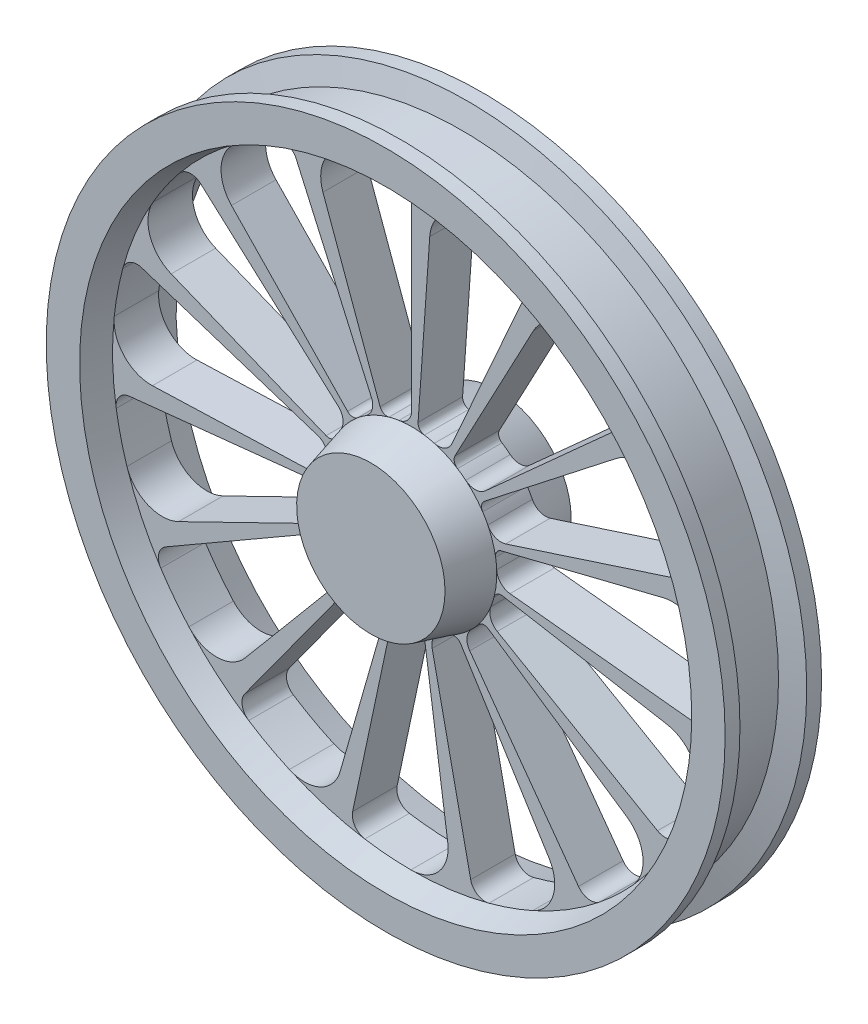
from build123d import *

# Parameters (mm, degrees)
CUT_EXTRUDE1_REACH = 117


with BuildPart() as part:
    # Sketch1 → Revolve2 (revolve)
    with BuildSketch(Plane(origin=(0, 0, 0), x_dir=(0, 0, -1), z_dir=(1, 0, 0))):
        Polygon((0, 0), (170, 0), (170, 100), (115, 114.737205584), (115, 403.121778265), (150, 412.5), (150, 457.5), (130, 457.5), (121.961524227, 427.5), (48.038475773, 427.5), (40, 457.5), (20, 457.5), (20, 412.5), (55, 403.121778265), (55, 114.737205584), (0, 100), align=None)
    revolve(axis=Axis((0, 0, 0), (0, 0, -1)))

    # Sketch3 → Cut-Extrude1 (cut, up to next)
    with BuildSketch(Plane(origin=(0, 0, -115), x_dir=(-1, 0, 0), z_dir=(0, 0, -1)), mode=Mode.PRIVATE) as cut_extrude1_sk1:
        with BuildLine():
            ThreePointArc((21.044054457, 402.57212507), (6.231940753, 397.105963918), (0, 382.599394904))
            Line((0, 382.599394904), (0, 133.24456675))
            ThreePointArc((0, 133.24456675), (4.844558076, 120.194180546), (17.031258009, 113.46612973))
            ThreePointArc((17.031258009, 113.46612973), (23.794589812, 112.242789705), (30.472538424, 110.616683855))
            ThreePointArc((30.472538424, 110.616683855), (37.714753572, 111.371314729), (42.525319659, 116.837355519))
            Line((42.525319659, 116.837355519), (119.557929474, 328.482711546))
            ThreePointArc((119.557929474, 328.482711546), (116.274613155, 369.877649884), (82.849257452, 394.516373109))
            ThreePointArc((82.849257452, 394.516373109), (52.102580068, 399.74052742), (21.044054457, 402.57212507))
        make_face()
    cut_extrude1_tool1 = extrude(cut_extrude1_sk1.sketch, amount=-CUT_EXTRUDE1_REACH, mode=Mode.PRIVATE) & part.part
    add(cut_extrude1_tool1.solids().sort_by_distance((-47.75418, 277.635932, -115))[0], mode=Mode.SUBTRACT)
    # Sketch3 → Cut-Extrude1 (cut, up to next)
    with BuildSketch(Plane(origin=(0, 0, -115), x_dir=(-1, 0, 0), z_dir=(0, 0, -1)), mode=Mode.PRIVATE) as cut_extrude1_sk2:
        with BuildLine():
            ThreePointArc((236.150828051, 326.710811762), (210.187195577, 343.989114547), (182.965535106, 359.208548165))
            ThreePointArc((182.965535106, 359.208548165), (167.210707876, 360.239590879), (155.617193526, 349.521939311))
            Line((155.617193526, 349.521939311), (54.195447788, 121.72496871))
            ThreePointArc((54.195447788, 121.72496871), (53.313101537, 107.832388384), (61.709661101, 96.729230701))
            ThreePointArc((61.709661101, 96.729230701), (67.390694934, 92.860759105), (72.82990772, 88.659071091))
            ThreePointArc((72.82990772, 88.659071091), (79.7529365, 86.40278642), (86.370846379, 89.439629654))
            Line((86.370846379, 89.439629654), (242.827558799, 251.45529816))
            ThreePointArc((242.827558799, 251.45529816), (256.664938349, 290.606901105), (236.150828051, 326.710811762))
        make_face()
    cut_extrude1_tool2 = extrude(cut_extrude1_sk2.sketch, amount=-CUT_EXTRUDE1_REACH, mode=Mode.PRIVATE) & part.part
    add(cut_extrude1_tool2.solids().sort_by_distance((-156.550321, 234.20967, -115))[0], mode=Mode.SUBTRACT)
    # Sketch3 → Cut-Extrude1 (cut, up to next)
    with BuildSketch(Plane(origin=(0, 0, -115), x_dir=(-1, 0, 0), z_dir=(0, 0, -1)), mode=Mode.PRIVATE) as cut_extrude1_sk3:
        with BuildLine():
            ThreePointArc((348.619775118, 202.413982986), (331.928535479, 228.758858727), (313.250612546, 253.734549975))
            ThreePointArc((313.250612546, 253.734549975), (299.277224547, 261.084519902), (284.326760554, 256.008965105))
            Line((284.326760554, 256.008965105), (99.020010304, 89.158017744))
            ThreePointArc((99.020010304, 89.158017744), (92.563325408, 76.825396644), (95.717903174, 63.266968927))
            ThreePointArc((95.717903174, 63.266968927), (99.334336676, 57.422259641), (102.594324332, 51.371499492))
            ThreePointArc((102.594324332, 51.371499492), (108.001112174, 46.494431395), (115.282069106, 46.576979287))
            Line((115.282069106, 46.576979287), (324.110097188, 130.948979322))
            ThreePointArc((324.110097188, 130.948979322), (352.675563975, 161.087579045), (348.619775118, 202.413982986))
        make_face()
    cut_extrude1_tool3 = extrude(cut_extrude1_sk3.sketch, amount=-CUT_EXTRUDE1_REACH, mode=Mode.PRIVATE) & part.part
    add(cut_extrude1_tool3.solids().sort_by_distance((-238.27749, 150.286428, -115))[0], mode=Mode.SUBTRACT)
    # Sketch3 → Cut-Extrude1 (cut, up to next)
    with BuildSketch(Plane(origin=(0, 0, -115), x_dir=(-1, 0, 0), z_dir=(0, 0, -1)), mode=Mode.PRIVATE) as cut_extrude1_sk4:
        with BuildLine():
            ThreePointArc((400.809195955, 43.11793768), (396.276416122, 73.974118023), (389.371813284, 104.387542988))
            ThreePointArc((389.371813284, 104.387542988), (379.595990245, 116.785563556), (363.873647654, 118.229715063))
            Line((363.873647654, 118.229715063), (126.723113469, 41.174835534))
            ThreePointArc((126.723113469, 41.174835534), (115.808509405, 32.534595887), (113.175650218, 18.865273462))
            ThreePointArc((113.175650218, 18.865273462), (114.102169183, 12.054929821), (114.619250226, 5.201328936))
            ThreePointArc((114.619250226, 5.201328936), (117.574914394, -1.453233208), (124.259974779, -4.339253936))
            Line((124.259974779, -4.339253936), (349.351055326, -12.199607675))
            ThreePointArc((349.351055326, -12.199607675), (387.705380633, 3.714751133), (400.809195955, 43.11793768))
        make_face()
    cut_extrude1_tool4 = extrude(cut_extrude1_sk4.sketch, amount=-CUT_EXTRUDE1_REACH, mode=Mode.PRIVATE) & part.part
    add(cut_extrude1_tool4.solids().sort_by_distance((-278.804316, 40.377297, -115))[0], mode=Mode.SUBTRACT)
    # Sketch3 → Cut-Extrude1 (cut, up to next)
    with BuildSketch(Plane(origin=(0, 0, -115), x_dir=(-1, 0, 0), z_dir=(0, 0, -1)), mode=Mode.PRIVATE) as cut_extrude1_sk5:
        with BuildLine():
            ThreePointArc((383.695065574, -123.633590766), (392.104504358, -93.60141972), (398.167090174, -63.009018512))
            ThreePointArc((398.167090174, -63.009018512), (394.279160708, -47.706677692), (380.503475387, -39.992526796))
            Line((380.503475387, -39.992526796), (132.514639072, -13.927849801))
            ThreePointArc((132.514639072, -13.927849801), (119.029350038, -17.381732066), (111.064299172, -28.798399169))
            ThreePointArc((111.064299172, -28.798399169), (109.140700052, -35.39680688), (106.825466474, -41.868198646))
            ThreePointArc((106.825466474, -41.868198646), (106.818945781, -49.149620586), (111.752201947, -54.505190733))
            Line((111.752201947, -54.505190733), (314.186042243, -153.238771675))
            ThreePointArc((314.186042243, -153.238771675), (355.697414787, -154.300390997), (383.695065574, -123.633590766))
        make_face()
    cut_extrude1_tool5 = extrude(cut_extrude1_sk5.sketch, amount=-CUT_EXTRUDE1_REACH, mode=Mode.PRIVATE) & part.part
    add(cut_extrude1_tool5.solids().sort_by_distance((-271.123342, -76.513435, -115))[0], mode=Mode.SUBTRACT)
    # Sketch3 → Cut-Extrude1 (cut, up to next)
    with BuildSketch(Plane(origin=(0, 0, -115), x_dir=(-1, 0, 0), z_dir=(0, 0, -1)), mode=Mode.PRIVATE) as cut_extrude1_sk6:
        with BuildLine():
            ThreePointArc((300.236572595, -269.007748193), (320.134161633, -244.992421652), (338.115659938, -219.510748293))
            ThreePointArc((338.115659938, -219.510748293), (340.787882371, -203.950000966), (331.340795459, -191.299697452))
            Line((331.340795459, -191.299697452), (115.393179722, -66.622283375))
            ThreePointArc((115.393179722, -66.622283375), (101.668934702, -64.292600637), (89.74892181, -71.482566959))
            ThreePointArc((89.74892181, -71.482566959), (85.30781237, -76.728114103), (80.560589089, -81.698334321))
            ThreePointArc((80.560589089, -81.698334321), (77.593011023, -88.347592055), (79.921458161, -95.246684889))
            Line((79.921458161, -95.246684889), (224.695408166, -267.781559922))
            ThreePointArc((224.695408166, -267.781559922), (262.186134514, -285.635593749), (300.236572595, -269.007748193))
        make_face()
    cut_extrude1_tool6 = extrude(cut_extrude1_sk6.sketch, amount=-CUT_EXTRUDE1_REACH, mode=Mode.PRIVATE) & part.part
    add(cut_extrude1_tool6.solids().sort_by_distance((-216.56268, -180.174299, -115))[0], mode=Mode.SUBTRACT)
    # Sketch3 → Cut-Extrude1 (cut, up to next)
    with BuildSketch(Plane(origin=(0, 0, -115), x_dir=(-1, 0, 0), z_dir=(0, 0, -1)), mode=Mode.PRIVATE) as cut_extrude1_sk7:
        with BuildLine():
            ThreePointArc((164.864448651, -367.868022098), (192.809714035, -354.022008193), (219.600960414, -338.057075501))
            ThreePointArc((219.600960414, -338.057075501), (228.371283212, -324.928516245), (224.886281861, -309.529412515))
            Line((224.886281861, -309.529412515), (78.319191284, -107.797118909))
            ThreePointArc((78.319191284, -107.797118909), (66.729036923, -100.086694478), (52.915140525, -101.806749523))
            ThreePointArc((52.915140525, -101.806749523), (46.724428933, -104.792433344), (40.366053981, -107.402085786))
            ThreePointArc((40.366053981, -107.402085786), (34.950539748, -112.269462245), (34.271568195, -119.519161938))
            Line((34.271568195, -119.519161938), (96.352896723, -336.022483739))
            ThreePointArc((96.352896723, -336.022483739), (123.340489698, -367.581807424), (164.864448651, -367.868022098))
        make_face()
    cut_extrude1_tool7 = extrude(cut_extrude1_sk7.sketch, amount=-CUT_EXTRUDE1_REACH, mode=Mode.PRIVATE) & part.part
    add(cut_extrude1_tool7.solids().sort_by_distance((-124.556363, -252.68139, -115))[0], mode=Mode.SUBTRACT)
    # Sketch3 → Cut-Extrude1 (cut, up to next)
    with BuildSketch(Plane(origin=(0, 0, -115), x_dir=(-1, 0, 0), z_dir=(0, 0, -1)), mode=Mode.PRIVATE) as cut_extrude1_sk8:
        with BuildLine():
            ThreePointArc((0.985763789, -403.120573007), (32.146715258, -401.83797333), (63.115259823, -398.150263203))
            ThreePointArc((63.115259823, -398.150263203), (76.467214497, -389.723939183), (79.5468871, -374.238680168))
            Line((79.5468871, -374.238680168), (27.703103165, -130.332853278))
            ThreePointArc((27.703103165, -130.332853278), (20.251082445, -118.574889584), (6.931850724, -114.527620209))
            ThreePointArc((6.931850724, -114.527620209), (0.061967254, -114.73718885), (-6.808138575, -114.535040901))
            ThreePointArc((-6.808138575, -114.535040901), (-13.735197365, -116.778922477), (-17.304187259, -123.12569009))
            Line((-17.304187259, -123.12569009), (-48.649905902, -346.162067449))
            ThreePointArc((-48.649905902, -346.162067449), (-36.831846301, -385.969787219), (0.985763789, -403.120573007))
        make_face()
    cut_extrude1_tool8 = extrude(cut_extrude1_sk8.sketch, amount=-CUT_EXTRUDE1_REACH, mode=Mode.PRIVATE) & part.part
    add(cut_extrude1_tool8.solids().sort_by_distance((-11.013119, -281.497573, -115))[0], mode=Mode.SUBTRACT)
    # Sketch3 → Cut-Extrude1 (cut, up to next)
    with BuildSketch(Plane(origin=(0, 0, -115), x_dir=(-1, 0, 0), z_dir=(0, 0, -1)), mode=Mode.PRIVATE) as cut_extrude1_sk9:
        with BuildLine():
            ThreePointArc((-185.240697826, -296.447084914), (-190.635621467, -337.620084379), (-163.063368588, -368.669914607))
            ThreePointArc((-163.063368588, -368.669914607), (-134.07474263, -380.172502294), (-104.283642576, -389.399653316))
            ThreePointArc((-104.283642576, -389.399653316), (-88.658730287, -387.132552505), (-79.5468871, -374.238680168))
            Line((-79.5468871, -374.238680168), (-27.703103165, -130.332853278))
            ThreePointArc((-27.703103165, -130.332853278), (-29.728468162, -116.560409062), (-40.250019041, -107.44562491))
            ThreePointArc((-40.250019041, -107.44562491), (-46.611209125, -104.84284205), (-52.805142121, -101.863846927))
            ThreePointArc((-52.805142121, -101.863846927), (-60.045994073, -101.096246109), (-65.887891532, -105.442667864))
            Line((-65.887891532, -105.442667864), (-185.240697826, -296.447084914))
        make_face()
    cut_extrude1_tool9 = extrude(cut_extrude1_sk9.sketch, amount=-CUT_EXTRUDE1_REACH, mode=Mode.PRIVATE) & part.part
    add(cut_extrude1_tool9.solids().sort_by_distance((104.434393, -261.640269, -115))[0], mode=Mode.SUBTRACT)
    # Sketch3 → Cut-Extrude1 (cut, up to next)
    with BuildSketch(Plane(origin=(0, 0, -115), x_dir=(-1, 0, 0), z_dir=(0, 0, -1)), mode=Mode.PRIVATE) as cut_extrude1_sk10:
        with BuildLine():
            ThreePointArc((-289.801690237, -195.47370826), (-311.476765811, -230.892801767), (-298.917363152, -270.47287871))
            ThreePointArc((-298.917363152, -270.47287871), (-277.113459487, -292.771751852), (-253.650955786, -313.318305785))
            ThreePointArc((-253.650955786, -313.318305785), (-238.454775165, -317.60243051), (-224.886281861, -309.529412515))
            Line((-224.886281861, -309.529412515), (-78.319191284, -107.797118909))
            ThreePointArc((-78.319191284, -107.797118909), (-74.56769655, -94.391574896), (-80.472294854, -81.785304952))
            ThreePointArc((-80.472294854, -81.785304952), (-85.224883997, -76.820215392), (-89.671656875, -71.579468415))
            ThreePointArc((-89.671656875, -71.579468415), (-95.974292905, -67.933110359), (-103.078980787, -69.527650448))
            Line((-103.078980787, -69.527650448), (-289.801690237, -195.47370826))
        make_face()
    cut_extrude1_tool10 = extrude(cut_extrude1_sk10.sketch, amount=-CUT_EXTRUDE1_REACH, mode=Mode.PRIVATE) & part.part
    add(cut_extrude1_tool10.solids().sort_by_distance((201.82425, -196.542985, -115))[0], mode=Mode.SUBTRACT)
    # Sketch3 → Cut-Extrude1 (cut, up to next)
    with BuildSketch(Plane(origin=(0, 0, -115), x_dir=(-1, 0, 0), z_dir=(0, 0, -1)), mode=Mode.PRIVATE) as cut_extrude1_sk11:
        with BuildLine():
            ThreePointArc((-344.25333764, -60.701151625), (-378.460747669, -84.242056135), (-383.085830047, -125.508624916))
            ThreePointArc((-383.085830047, -125.508624916), (-372.236741702, -154.748105768), (-359.159714395, -183.061376777))
            ThreePointArc((-359.159714395, -183.061376777), (-347.019823124, -193.155962952), (-331.340795459, -191.299697452))
            Line((-331.340795459, -191.299697452), (-115.393179722, -66.622283375))
            ThreePointArc((-115.393179722, -66.622283375), (-106.513492778, -55.901579909), (-106.780179819, -41.983562771))
            ThreePointArc((-106.780179819, -41.983562771), (-109.102402183, -35.514675603), (-111.033127513, -28.918349534))
            ThreePointArc((-111.033127513, -28.918349534), (-115.307764594, -23.023722674), (-122.44677782, -21.590670631))
            Line((-122.44677782, -21.590670631), (-344.25333764, -60.701151625))
        make_face()
    cut_extrude1_tool11 = extrude(cut_extrude1_sk11.sketch, amount=-CUT_EXTRUDE1_REACH, mode=Mode.PRIVATE) & part.part
    add(cut_extrude1_tool11.solids().sort_by_distance((264.31686, -97.461633, -115))[0], mode=Mode.SUBTRACT)
    # Sketch3 → Cut-Extrude1 (cut, up to next)
    with BuildSketch(Plane(origin=(0, 0, -115), x_dir=(-1, 0, 0), z_dir=(0, 0, -1)), mode=Mode.PRIVATE) as cut_extrude1_sk12:
        with BuildLine():
            ThreePointArc((-339.180455522, 84.567185579), (-380.005428047, 76.974906318), (-401.015276703, 41.157210336))
            ThreePointArc((-401.015276703, 41.157210336), (-402.996909612, 10.032893646), (-402.56649552, -21.151472664))
            ThreePointArc((-402.56649552, -21.151472664), (-395.581991088, -35.311074634), (-380.503475387, -39.992526796))
            Line((-380.503475387, -39.992526796), (-132.514639072, -13.927849801))
            ThreePointArc((-132.514639072, -13.927849801), (-120.04213846, -7.745693906), (-114.624801626, 5.077518822))
            ThreePointArc((-114.624801626, 5.077518822), (-114.115123866, 11.931674239), (-113.1959617, 18.743014695))
            ThreePointArc((-113.1959617, 18.743014695), (-114.703476248, 25.866675825), (-120.642414575, 30.079532284))
            Line((-120.642414575, 30.079532284), (-339.180455522, 84.567185579))
        make_face()
    cut_extrude1_tool12 = extrude(cut_extrude1_sk12.sketch, amount=-CUT_EXTRUDE1_REACH, mode=Mode.PRIVATE) & part.part
    add(cut_extrude1_tool12.solids().sort_by_distance((281.106685, 18.47172, -115))[0], mode=Mode.SUBTRACT)
    # Sketch3 → Cut-Extrude1 (cut, up to next)
    with BuildSketch(Plane(origin=(0, 0, -115), x_dir=(-1, 0, 0), z_dir=(0, 0, -1)), mode=Mode.PRIVATE) as cut_extrude1_sk13:
        with BuildLine():
            ThreePointArc((-275.460191287, 215.213088127), (-315.843717675, 224.882208174), (-349.605538906, 200.70659002))
            ThreePointArc((-349.605538906, 200.70659002), (-364.075250738, 173.079114603), (-376.365872369, 144.415713228))
            ThreePointArc((-376.365872369, 144.415713228), (-375.744439044, 128.63941928), (-363.873647654, 118.229715063))
            Line((-363.873647654, 118.229715063), (-126.723113469, 41.174835534))
            ThreePointArc((-126.723113469, 41.174835534), (-112.814407853, 41.74949294), (-102.649753898, 51.260651282))
            ThreePointArc((-102.649753898, 51.260651282), (-99.39630393, 57.314929209), (-95.786185757, 63.163541409))
            ThreePointArc((-95.786185757, 63.163541409), (-94.265914809, 70.284491082), (-97.977881847, 76.548710803))
            Line((-97.977881847, 76.548710803), (-275.460191287, 215.213088127))
        make_face()
    cut_extrude1_tool13 = extrude(cut_extrude1_sk13.sketch, amount=-CUT_EXTRUDE1_REACH, mode=Mode.PRIVATE) & part.part
    add(cut_extrude1_tool13.solids().sort_by_distance((249.290609, 131.211146, -115))[0], mode=Mode.SUBTRACT)
    # Sketch3 → Cut-Extrude1 (cut, up to next)
    with BuildSketch(Plane(origin=(0, 0, -115), x_dir=(-1, 0, 0), z_dir=(0, 0, -1)), mode=Mode.PRIVATE) as cut_extrude1_sk14:
        with BuildLine():
            ThreePointArc((-164.110357501, 308.646692589), (-197.069759166, 333.905333246), (-237.745827367, 325.551976927))
            ThreePointArc((-237.745827367, 325.551976927), (-262.201673492, 306.19838427), (-285.088170709, 285.012110328))
            ThreePointArc((-285.088170709, 285.012110328), (-290.937259957, 270.346988948), (-284.326760554, 256.008965105))
            Line((-284.326760554, 256.008965105), (-99.020010304, 89.158017744))
            ThreePointArc((-99.020010304, 89.158017744), (-86.080041242, 84.025813175), (-72.925631177, 88.580351448))
            ThreePointArc((-72.925631177, 88.580351448), (-67.490960057, 92.787912228), (-61.814108105, 96.662517991))
            ThreePointArc((-61.814108105, 96.662517991), (-57.528920322, 102.549479317), (-58.372083247, 109.7819218))
            Line((-58.372083247, 109.7819218), (-164.110357501, 308.646692589))
        make_face()
    cut_extrude1_tool14 = extrude(cut_extrude1_sk14.sketch, amount=-CUT_EXTRUDE1_REACH, mode=Mode.PRIVATE) & part.part
    add(cut_extrude1_tool14.solids().sort_by_distance((174.369923, 221.262972, -115))[0], mode=Mode.SUBTRACT)
    # Sketch3 → Cut-Extrude1 (cut, up to next)
    with BuildSketch(Plane(origin=(0, 0, -115), x_dir=(-1, 0, 0), z_dir=(0, 0, -1)), mode=Mode.PRIVATE) as cut_extrude1_sk15:
        with BuildLine():
            ThreePointArc((-24.384352007, 348.712479935), (-44.220648976, 385.193192764), (-84.777702422, 394.106469477))
            ThreePointArc((-84.777702422, 394.106469477), (-114.991044871, 386.373171572), (-144.516134388, 376.327324298))
            ThreePointArc((-144.516134388, 376.327324298), (-155.824385542, 365.309108202), (-155.617193526, 349.521939311))
            Line((-155.617193526, 349.521939311), (-54.195447788, 121.72496871))
            ThreePointArc((-54.195447788, 121.72496871), (-44.461653488, 111.773306962), (-30.592004317, 110.583704121))
            ThreePointArc((-30.592004317, 110.583704121), (-23.915816055, 112.217022272), (-17.153809599, 113.44766706))
            ThreePointArc((-17.153809599, 113.44766706), (-10.844652876, 117.082730945), (-8.67322116, 124.032841181))
            Line((-8.67322116, 124.032841181), (-24.384352007, 348.712479935))
        make_face()
    cut_extrude1_tool15 = extrude(cut_extrude1_sk15.sketch, amount=-CUT_EXTRUDE1_REACH, mode=Mode.PRIVATE) & part.part
    add(cut_extrude1_tool15.solids().sort_by_distance((69.299093, 273.05642, -115))[0], mode=Mode.SUBTRACT)


solid = part.part
